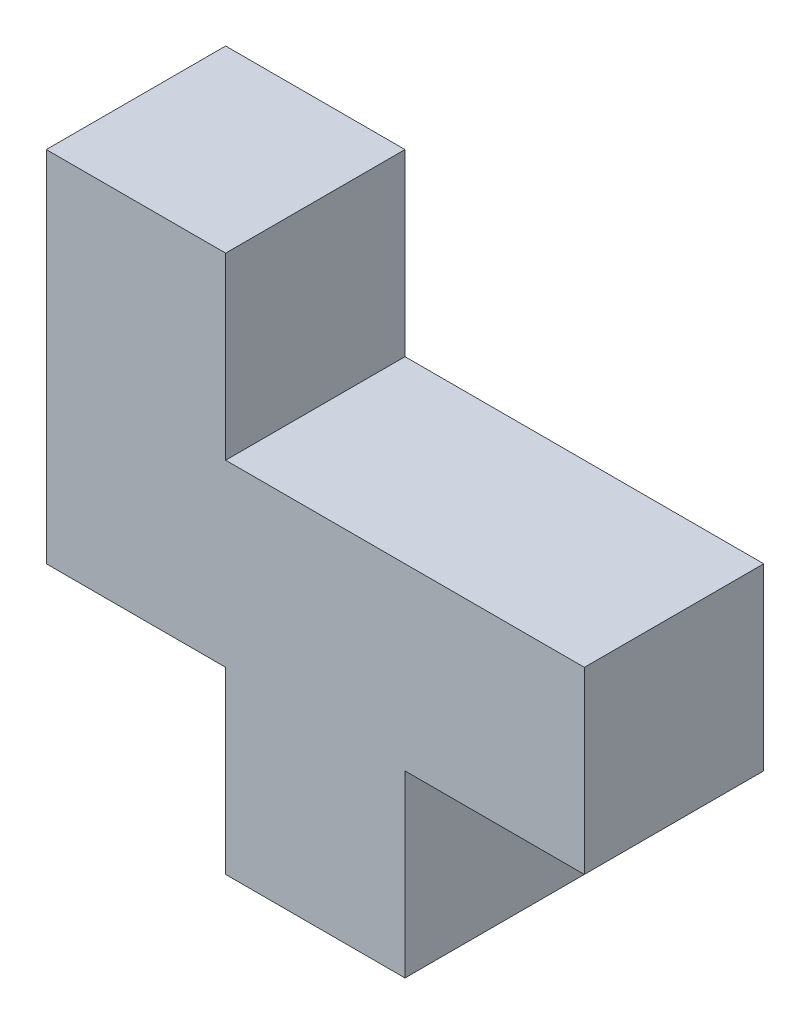
from build123d import *

# Parameters (mm, degrees)
BOSS_EXTRUDE1_DEPTH = 25.4


with BuildPart() as part:
    # Sketch1 → Boss-Extrude1 (new body)
    with BuildSketch(Plane.XY):
        Polygon((50.8, 0), (50.8, 25.4), (76.2, 25.4), (76.2, 50.8), (25.4, 50.8), (25.4, 76.2), (0, 76.2), (0, 25.4), (25.4, 25.4), (25.4, 0), align=None)
    extrude(amount=BOSS_EXTRUDE1_DEPTH)


solid = part.part
